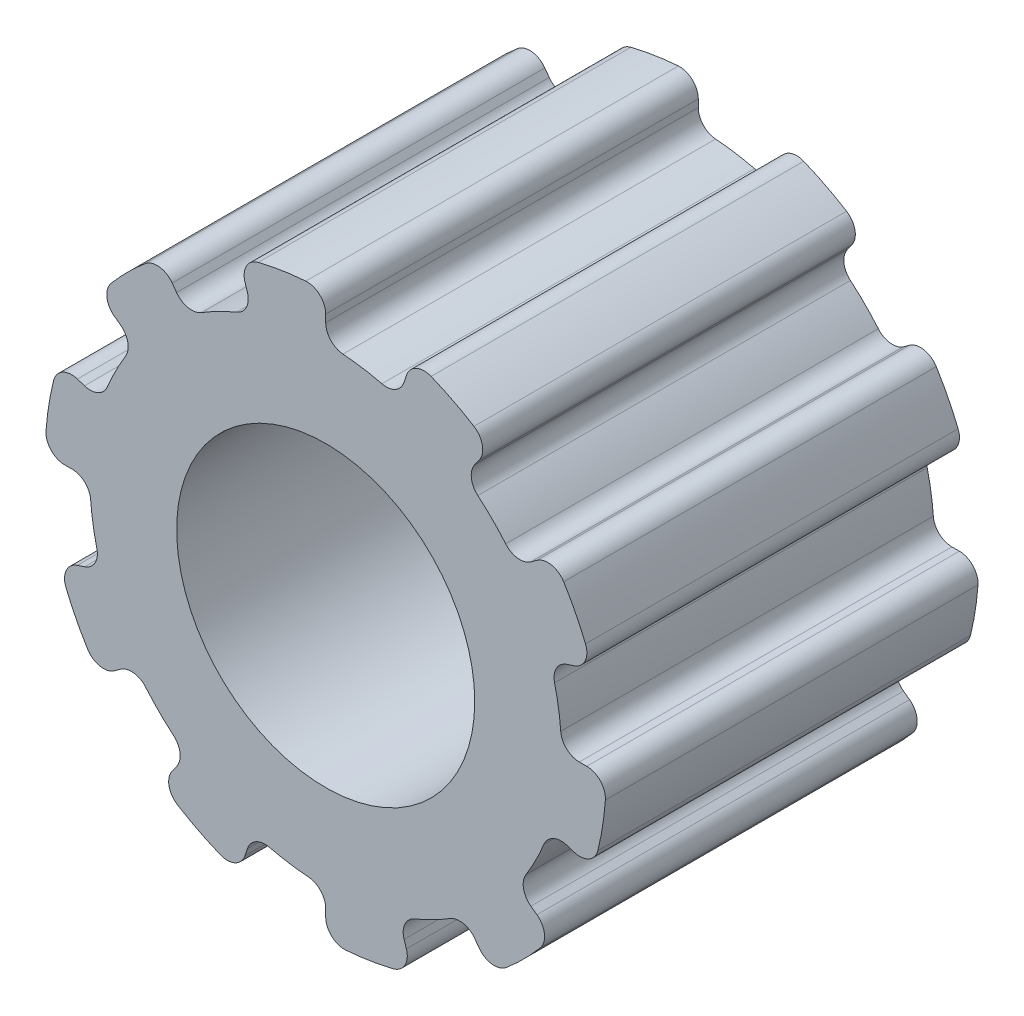
from build123d import *

# Parameters (mm, degrees)
ESQUISSE1_R      = 4
EXTRUSION1_DEPTH = 10


with BuildPart() as part:
    # Esquisse1 → Extrusion1 (new body)
    with BuildSketch(Plane.XY):
        with BuildLine():
            Line((4.000854566, 5.506703891), (4.118719306, 5.668930788))
            ThreePointArc((4.118719306, 5.668930788), (4.204956471, 6.058576718), (3.97856745, 6.387223657))
            ThreePointArc((3.97856745, 6.387223657), (3.416278511, 6.704824095), (2.828829213, 6.973044549))
            ThreePointArc((2.828829213, 6.973044549), (2.429880127, 6.96302329), (2.165338881, 6.664227827))
            Line((2.165338881, 6.664227827), (2.10337372, 6.473518672))
            ThreePointArc((2.10337372, 6.473518672), (1.871017944, 6.191143724), (1.508589384, 6.142457413))
            ThreePointArc((1.508589384, 6.142457413), (0.989447991, 6.247128754), (0.463369963, 6.308003906))
            ThreePointArc((0.463369963, 6.308003906), (0.133724818, 6.466303924), (0, 6.806660341))
            Line((0, 6.806660341), (0, 7.007183814))
            ThreePointArc((0, 7.007183814), (-0.159260799, 7.373102927), (-0.535587189, 7.505915758))
            ThreePointArc((-0.535587189, 7.505915758), (-1.177169349, 7.432354763), (-1.810081842, 7.304055635))
            ThreePointArc((-1.810081842, 7.304055635), (-2.126948085, 7.061451877), (-2.165338881, 6.664227827))
            Line((-2.165338881, 6.664227827), (-2.10337372, 6.473518672))
            ThreePointArc((-2.10337372, 6.473518672), (-2.125377663, 6.108497242), (-2.389971431, 5.856079026))
            ThreePointArc((-2.389971431, 5.856079026), (-2.871489911, 5.635616265), (-3.332877492, 5.375644391))
            ThreePointArc((-3.332877492, 5.375644391), (-3.692612433, 5.309951241), (-4.000854566, 5.506703891))
            Line((-4.000854566, 5.506703891), (-4.118719306, 5.668930788))
            ThreePointArc((-4.118719306, 5.668930788), (-4.462645857, 5.87135442), (-4.845165725, 5.757603156))
            ThreePointArc((-4.845165725, 5.757603156), (-5.320978528, 5.320978528), (-5.757603156, 4.845165725))
            ThreePointArc((-5.757603156, 4.845165725), (-5.87135442, 4.462645857), (-5.668930788, 4.118719306))
            Line((-5.668930788, 4.118719306), (-5.506703891, 4.000854566))
            ThreePointArc((-5.506703891, 4.000854566), (-5.309951241, 3.692612433), (-5.375644391, 3.332877492))
            ThreePointArc((-5.375644391, 3.332877492), (-5.635616265, 2.871489911), (-5.856079026, 2.389971431))
            ThreePointArc((-5.856079026, 2.389971431), (-6.108497242, 2.125377663), (-6.473518672, 2.10337372))
            Line((-6.473518672, 2.10337372), (-6.664227827, 2.165338881))
            ThreePointArc((-6.664227827, 2.165338881), (-7.061451877, 2.126948085), (-7.304055635, 1.810081842))
            ThreePointArc((-7.304055635, 1.810081842), (-7.432354763, 1.177169349), (-7.505915758, 0.535587189))
            ThreePointArc((-7.505915758, 0.535587189), (-7.373102927, 0.159260799), (-7.007183814, 0))
            Line((-7.007183814, 0), (-6.806660341, 0))
            ThreePointArc((-6.806660341, 0), (-6.466303924, -0.133724818), (-6.308003906, -0.463369963))
            ThreePointArc((-6.308003906, -0.463369963), (-6.247128754, -0.989447991), (-6.142457413, -1.508589384))
            ThreePointArc((-6.142457413, -1.508589384), (-6.191143724, -1.871017944), (-6.473518672, -2.10337372))
            Line((-6.473518672, -2.10337372), (-6.664227827, -2.165338881))
            ThreePointArc((-6.664227827, -2.165338881), (-6.96302329, -2.429880127), (-6.973044549, -2.828829213))
            ThreePointArc((-6.973044549, -2.828829213), (-6.704824095, -3.416278511), (-6.387223657, -3.97856745))
            ThreePointArc((-6.387223657, -3.97856745), (-6.058576718, -4.204956471), (-5.668930788, -4.118719306))
            Line((-5.668930788, -4.118719306), (-5.506703891, -4.000854566))
            ThreePointArc((-5.506703891, -4.000854566), (-5.152748289, -3.908983733), (-4.83092033, -4.082625842))
            ThreePointArc((-4.83092033, -4.082625842), (-4.472450391, -4.472450391), (-4.082625842, -4.83092033))
            ThreePointArc((-4.082625842, -4.83092033), (-3.908983733, -5.152748289), (-4.000854566, -5.506703891))
            Line((-4.000854566, -5.506703891), (-4.118719306, -5.668930788))
            ThreePointArc((-4.118719306, -5.668930788), (-4.204956471, -6.058576718), (-3.97856745, -6.387223657))
            ThreePointArc((-3.97856745, -6.387223657), (-3.416278511, -6.704824095), (-2.828829213, -6.973044549))
            ThreePointArc((-2.828829213, -6.973044549), (-2.429880127, -6.96302329), (-2.165338881, -6.664227827))
            Line((-2.165338881, -6.664227827), (-2.10337372, -6.473518672))
            ThreePointArc((-2.10337372, -6.473518672), (-1.871017944, -6.191143724), (-1.508589384, -6.142457413))
            ThreePointArc((-1.508589384, -6.142457413), (-0.989447991, -6.247128754), (-0.463369963, -6.308003906))
            ThreePointArc((-0.463369963, -6.308003906), (-0.133724818, -6.466303924), (0, -6.806660341))
            Line((0, -6.806660341), (0, -7.007183814))
            ThreePointArc((0, -7.007183814), (0.159260799, -7.373102927), (0.535587189, -7.505915758))
            ThreePointArc((0.535587189, -7.505915758), (1.177169349, -7.432354763), (1.810081842, -7.304055635))
            ThreePointArc((1.810081842, -7.304055635), (2.126948085, -7.061451877), (2.165338881, -6.664227827))
            Line((2.165338881, -6.664227827), (2.10337372, -6.473518672))
            ThreePointArc((2.10337372, -6.473518672), (2.125377663, -6.108497242), (2.389971431, -5.856079026))
            ThreePointArc((2.389971431, -5.856079026), (2.871489911, -5.635616265), (3.332877492, -5.375644391))
            ThreePointArc((3.332877492, -5.375644391), (3.692612433, -5.309951241), (4.000854566, -5.506703891))
            Line((4.000854566, -5.506703891), (4.118719306, -5.668930788))
            ThreePointArc((4.118719306, -5.668930788), (4.462645857, -5.87135442), (4.845165725, -5.757603156))
            ThreePointArc((4.845165725, -5.757603156), (5.320978528, -5.320978528), (5.757603156, -4.845165725))
            ThreePointArc((5.757603156, -4.845165725), (5.87135442, -4.462645857), (5.668930788, -4.118719306))
            Line((5.668930788, -4.118719306), (5.506703891, -4.000854566))
            ThreePointArc((5.506703891, -4.000854566), (5.309951241, -3.692612433), (5.375644391, -3.332877492))
            ThreePointArc((5.375644391, -3.332877492), (5.635616265, -2.871489911), (5.856079026, -2.389971431))
            ThreePointArc((5.856079026, -2.389971431), (6.108497242, -2.125377663), (6.473518672, -2.10337372))
            Line((6.473518672, -2.10337372), (6.664227827, -2.165338881))
            ThreePointArc((6.664227827, -2.165338881), (7.061451877, -2.126948085), (7.304055635, -1.810081842))
            ThreePointArc((7.304055635, -1.810081842), (7.432354763, -1.177169349), (7.505915758, -0.535587189))
            ThreePointArc((7.505915758, -0.535587189), (7.373102927, -0.159260799), (7.007183814, 0))
            Line((7.007183814, 0), (6.806660341, 0))
            ThreePointArc((6.806660341, 0), (6.466303924, 0.133724818), (6.308003906, 0.463369963))
            ThreePointArc((6.308003906, 0.463369963), (6.247128754, 0.989447991), (6.142457413, 1.508589384))
            ThreePointArc((6.142457413, 1.508589384), (6.191143724, 1.871017944), (6.473518672, 2.10337372))
            Line((6.473518672, 2.10337372), (6.664227827, 2.165338881))
            ThreePointArc((6.664227827, 2.165338881), (6.96302329, 2.429880127), (6.973044549, 2.828829213))
            ThreePointArc((6.973044549, 2.828829213), (6.704824095, 3.416278511), (6.387223657, 3.97856745))
            ThreePointArc((6.387223657, 3.97856745), (6.058576718, 4.204956471), (5.668930788, 4.118719306))
            Line((5.668930788, 4.118719306), (5.506703891, 4.000854566))
            ThreePointArc((5.506703891, 4.000854566), (5.152748289, 3.908983733), (4.83092033, 4.082625842))
            ThreePointArc((4.83092033, 4.082625842), (4.472450391, 4.472450391), (4.082625842, 4.83092033))
            ThreePointArc((4.082625842, 4.83092033), (3.908983733, 5.152748289), (4.000854566, 5.506703891))
        make_face()
        Circle(ESQUISSE1_R, mode=Mode.SUBTRACT)
    extrude(amount=EXTRUSION1_DEPTH)


solid = part.part
